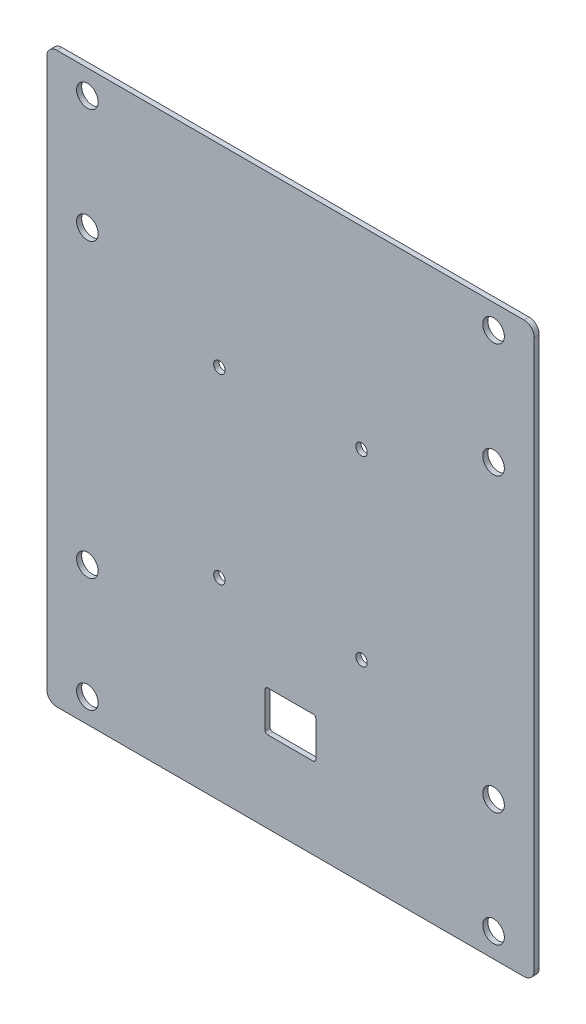
from build123d import *

# Parameters (mm, degrees)
SKETCH1_W                        = 304.8
SKETCH1_H                        = 355.6
BOSS_EXTRUDE1_DEPTH              = 3.175
F_17_32_0_53125_DIAMETER_HOLE1_D = 13.49375
FILLET1_R                        = 6.35
F_1_4_CLEARANCE_HOLE1_D          = 7.14248
SKETCH2_W                        = 31.75
SKETCH2_H                        = 25.4
CUT_EXTRUDE1_DEPTH               = 4.175
FILLET2_R                        = 1.5875


with BuildPart() as part:
    # Sketch1 → Boss-Extrude1 (new body)
    with BuildSketch(Plane.XY):
        Rectangle(SKETCH1_W, SKETCH1_H)
    extrude(amount=BOSS_EXTRUDE1_DEPTH)

    # 17/32 (0.53125) Diameter Hole1 (through all)
    with Locations(Plane.XY.offset(3.175)):
        with Locations((-127, 162.71875), (-127, 91.28125), (-127, -91.28125), (-127, -162.71875), (127, -162.71875), (127, -91.28125), (127, 91.28125), (127, 162.71875)):
            Hole(F_17_32_0_53125_DIAMETER_HOLE1_D / 2)

    # Fillet1
    fillet1_edges = [part.edges().sort_by_distance(p)[0] for p in [
        (152.4, -177.8, 1.5875),
        (-152.4, -177.8, 1.5875),
        (-152.4, 177.8, 1.5875),
        (152.4, 177.8, 1.5875),
    ]]
    fillet(fillet1_edges, radius=FILLET1_R)

    # 1/4 Clearance Hole1 (through all)
    with Locations(Plane(origin=(0, 0, 0), x_dir=(-1, 0, 0), z_dir=(0, 0, -1))):
        with Locations((-44.45, 56.9515625), (-44.45, -56.9515625), (44.45, 56.9515625), (44.45, -56.9515625)):
            Hole(F_1_4_CLEARANCE_HOLE1_D / 2)

    # Sketch2 → Cut-Extrude1 (cut, through all)
    with BuildSketch(Plane.XY.offset(3.175)):
        with Locations((0, -114.3)):
            Rectangle(SKETCH2_W, SKETCH2_H)
    extrude(amount=-CUT_EXTRUDE1_DEPTH, mode=Mode.SUBTRACT)

    # Fillet2
    fillet2_edges = [part.edges().sort_by_distance(p)[0] for p in [
        (-15.875, -101.6, 1.5875),
        (15.875, -101.6, 1.5875),
        (15.875, -127, 1.5875),
        (-15.875, -127, 1.5875),
    ]]
    fillet(fillet2_edges, radius=FILLET2_R)


solid = part.part
